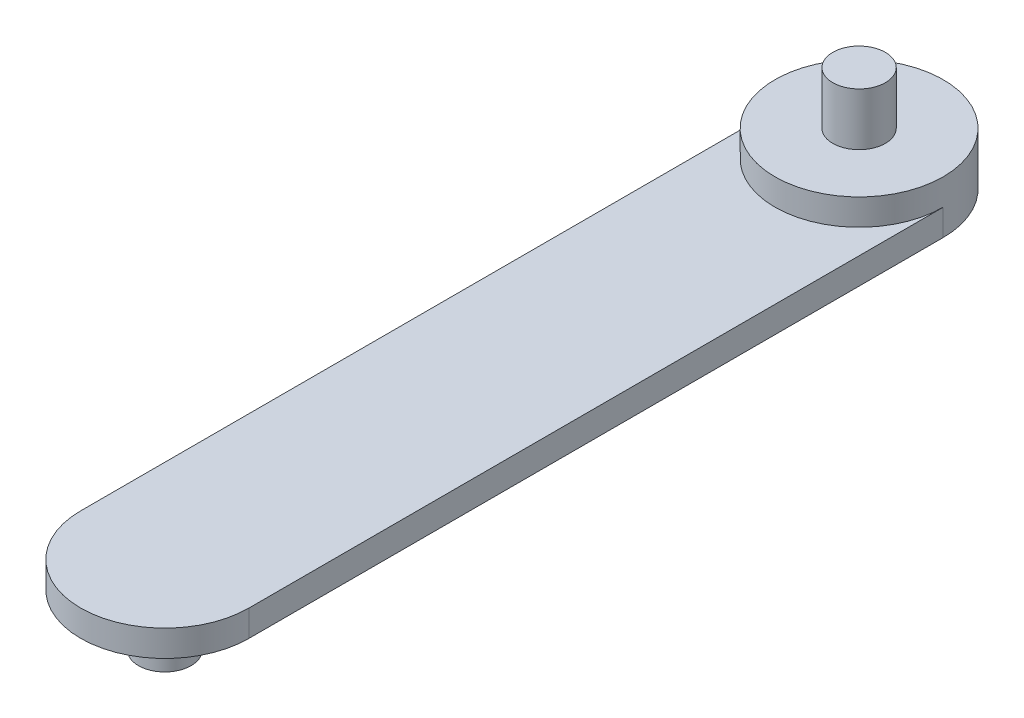
from build123d import *

# Parameters (mm, degrees)
BOSS_EXTRUDE1_DEPTH = 2.5
BOSS_EXTRUDE5_DEPTH = 1.25
SKETCH4_R           = 1.25
BOSS_EXTRUDE6_DEPTH = 2.5
SKETCH5_R           = 1.25
BOSS_EXTRUDE7_DEPTH = 2.5


with BuildPart() as part:
    # Sketch1 → Boss-Extrude1 (new body)
    with BuildSketch(Plane(origin=(0, 0, 0), x_dir=(1, 0, 0), z_dir=(0, 1, 0))):
        with BuildLine():
            ThreePointArc((4, 33), (0, 37), (-4, 33))
            ThreePointArc((-4, 33), (0, 29), (4, 33))
        make_face()
    extrude(amount=BOSS_EXTRUDE1_DEPTH)

    # Sketch1_5 → Boss-Extrude5 (add)
    with BuildSketch(Plane(origin=(0, 0, 0), x_dir=(1, 0, 0), z_dir=(0, 1, 0))):
        with BuildLine():
            Line((-4, 33), (-4, 0))
            ThreePointArc((-4, 0), (0, -4), (4, 0))
            Line((4, 0), (4, 33))
            ThreePointArc((4, 33), (0, 29), (-4, 33))
        make_face()
    extrude(amount=BOSS_EXTRUDE5_DEPTH)

    # Sketch4 → Boss-Extrude6 (add)
    with BuildSketch(Plane(origin=(0, 2.5, 0), x_dir=(1, 0, 0), z_dir=(0, 1, 0))):
        with Locations((0, 33)):
            Circle(SKETCH4_R)
    extrude(amount=BOSS_EXTRUDE6_DEPTH)

    # Sketch5 → Boss-Extrude7 (add)
    with BuildSketch(Plane.XZ):
        Circle(SKETCH5_R)
    extrude(amount=BOSS_EXTRUDE7_DEPTH)


solid = part.part
